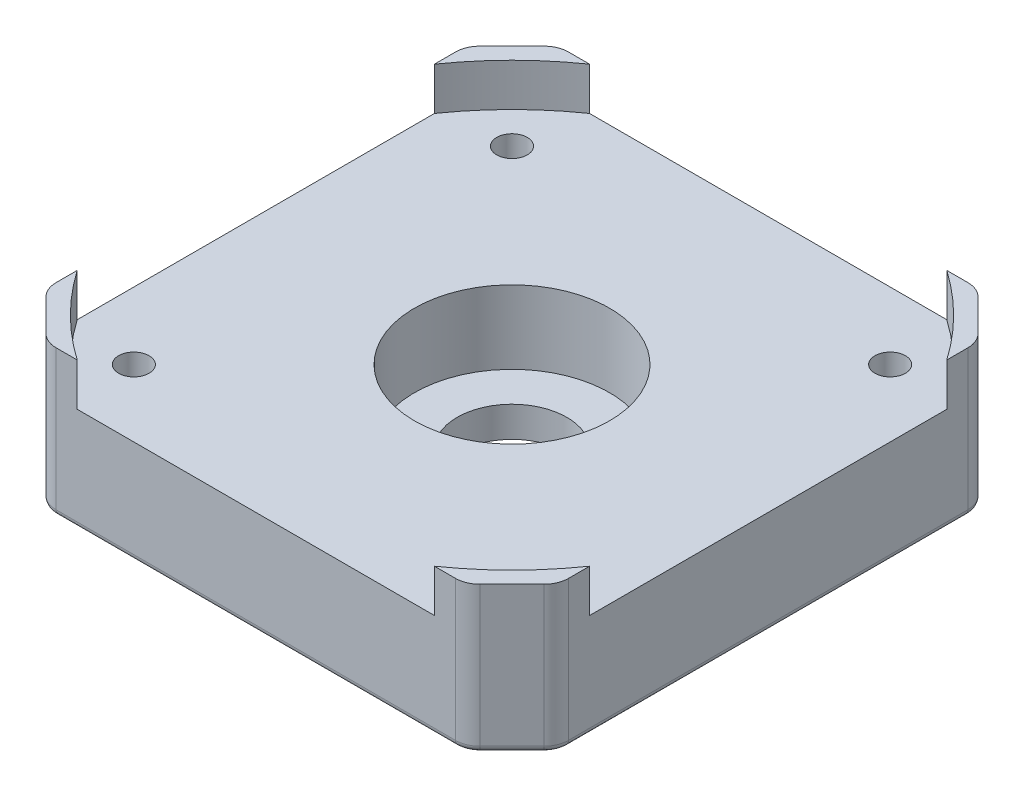
from build123d import *

# Parameters (mm, degrees)
SKETCH_1_R          = 1.25
SKETCH_1_R_2        = 4.5
EXTRUDE_1_DEPTH     = 8.5
EXTRUDE_2_DEPTH     = 12
CHAMFER_1_SIZE      = 2.5
SKETCH_2_R          = 8
CUT_EXTRUDE_1_DEPTH = 6
FILLET_1_R          = 2
FILLET_2_R          = 0.5


with BuildPart() as part:
    # Эскиз1 → Бобышка-Вытянуть1 (new body)
    with BuildSketch(Plane(origin=(0, 0, 0), x_dir=(1, 0, 0), z_dir=(0, 1, 0))):
        with BuildLine():
            ThreePointArc((-14.641038215, 21), (-18.101933598, 18.101933598), (-21, 14.641038215))
            Line((-21, 14.641038215), (-21, -14.641038215))
            ThreePointArc((-21, -14.641038215), (-18.101933598, -18.101933598), (-14.641038215, -21))
            Line((-14.641038215, -21), (14.641038215, -21))
            ThreePointArc((14.641038215, -21), (18.101933598, -18.101933598), (21, -14.641038215))
            Line((21, -14.641038215), (21, 14.641038215))
            ThreePointArc((21, 14.641038215), (18.101933598, 18.101933598), (14.641038215, 21))
            Line((14.641038215, 21), (-14.641038215, 21))
        make_face()
        with Locations((-15.5, -15.5)):
            Circle(SKETCH_1_R, mode=Mode.SUBTRACT)
        with Locations((15.5, -15.5)):
            Circle(SKETCH_1_R, mode=Mode.SUBTRACT)
        with Locations((-15.5, 15.5)):
            Circle(SKETCH_1_R, mode=Mode.SUBTRACT)
        with Locations((15.5, 15.5)):
            Circle(SKETCH_1_R, mode=Mode.SUBTRACT)
        Circle(SKETCH_1_R_2, mode=Mode.SUBTRACT)
    extrude(amount=EXTRUDE_1_DEPTH)

    # Эскиз1<4> → Бобышка-Вытянуть2 (add)
    with BuildSketch(Plane(origin=(0, 0, 0), x_dir=(1, 0, 0), z_dir=(0, 1, 0))):
        with BuildLine():
            Line((-17.2, 21), (-21, 17.2))
            Line((-21, 17.2), (-21, 14.641038215))
            ThreePointArc((-21, 14.641038215), (-18.101933598, 18.101933598), (-14.641038215, 21))
            Line((-14.641038215, 21), (-17.2, 21))
        make_face()
        with BuildLine():
            ThreePointArc((-14.641038215, -21), (-18.101933598, -18.101933598), (-21, -14.641038215))
            Line((-21, -14.641038215), (-21, -17.2))
            Line((-21, -17.2), (-17.2, -21))
            Line((-17.2, -21), (-14.641038215, -21))
        make_face()
        with BuildLine():
            Line((17.2, 21), (14.641038215, 21))
            ThreePointArc((14.641038215, 21), (18.101933598, 18.101933598), (21, 14.641038215))
            Line((21, 14.641038215), (21, 17.2))
            Line((21, 17.2), (17.2, 21))
        make_face()
        with BuildLine():
            ThreePointArc((21, -14.641038215), (18.101933598, -18.101933598), (14.641038215, -21))
            Line((14.641038215, -21), (17.2, -21))
            Line((17.2, -21), (21, -17.2))
            Line((21, -17.2), (21, -14.641038215))
        make_face()
    extrude(amount=EXTRUDE_2_DEPTH)

    # Фаска1
    chamfer_1_edges = [part.edges().sort_by_distance(p)[0] for p in [
        (-16.75, 0, -15.5),
        (14.25, 0, -15.5),
        (14.25, 0, 15.5),
        (-16.75, 0, 15.5),
    ]]
    chamfer(chamfer_1_edges, length=CHAMFER_1_SIZE)

    # Эскиз2 → Вырез-Вытянуть1 (cut)
    with BuildSketch(Plane(origin=(0, 8.5, 0), x_dir=(1, 0, 0), z_dir=(0, 1, 0))):
        Circle(SKETCH_2_R)
    extrude(amount=-CUT_EXTRUDE_1_DEPTH, mode=Mode.SUBTRACT)

    # Скругление1
    fillet_1_edges = [part.edges().sort_by_distance(p)[0] for p in [
        (21, 6, 17.2),
        (17.2, 6, 21),
        (-17.2, 6, 21),
        (-21, 6, 17.2),
        (-21, 6, -17.2),
        (-17.2, 6, -21),
        (17.2, 6, -21),
        (21, 6, -17.2),
    ]]
    fillet(fillet_1_edges, radius=FILLET_1_R)

    # Скругление2
    fillet_2_edges = [part.edges().sort_by_distance(p)[0] for p in [
        (-17.13693974, 0, 20.847759065),
        (-19.1, 0, 19.1),
        (-20.847759065, 0, 17.13693974),
        (-21, 0, 0),
        (-20.847759065, 0, -17.13693974),
        (-19.1, 0, -19.1),
        (-17.13693974, 0, -20.847759065),
        (0, 0, -21),
        (17.13693974, 0, -20.847759065),
        (19.1, 0, -19.1),
        (20.847759065, 0, -17.13693974),
        (21, 0, 0),
        (20.847759065, 0, 17.13693974),
        (19.1, 0, 19.1),
        (17.13693974, 0, 20.847759065),
        (0, 0, 21),
    ]]
    fillet(fillet_2_edges, radius=FILLET_2_R)


solid = part.part
